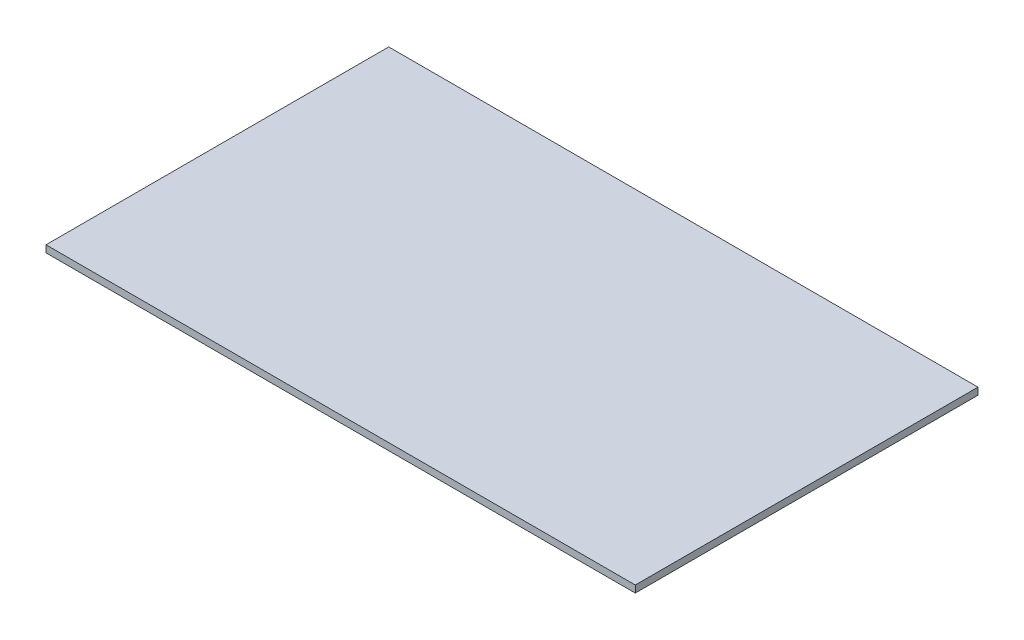
from build123d import *

# Parameters (mm, degrees)
SKETCH1_W           = 252.314915399
SKETCH1_H           = 146.739359082
BOSS_EXTRUDE1_DEPTH = 3


with BuildPart() as part:
    # Sketch1 → Boss-Extrude1 (new body)
    with BuildSketch(Plane(origin=(0, 0, 0), x_dir=(1, 0, 0), z_dir=(0, 1, 0))):
        with Locations((-20.155333478, -0.213283952)):
            Rectangle(SKETCH1_W, SKETCH1_H)
    extrude(amount=BOSS_EXTRUDE1_DEPTH)


solid = part.part
